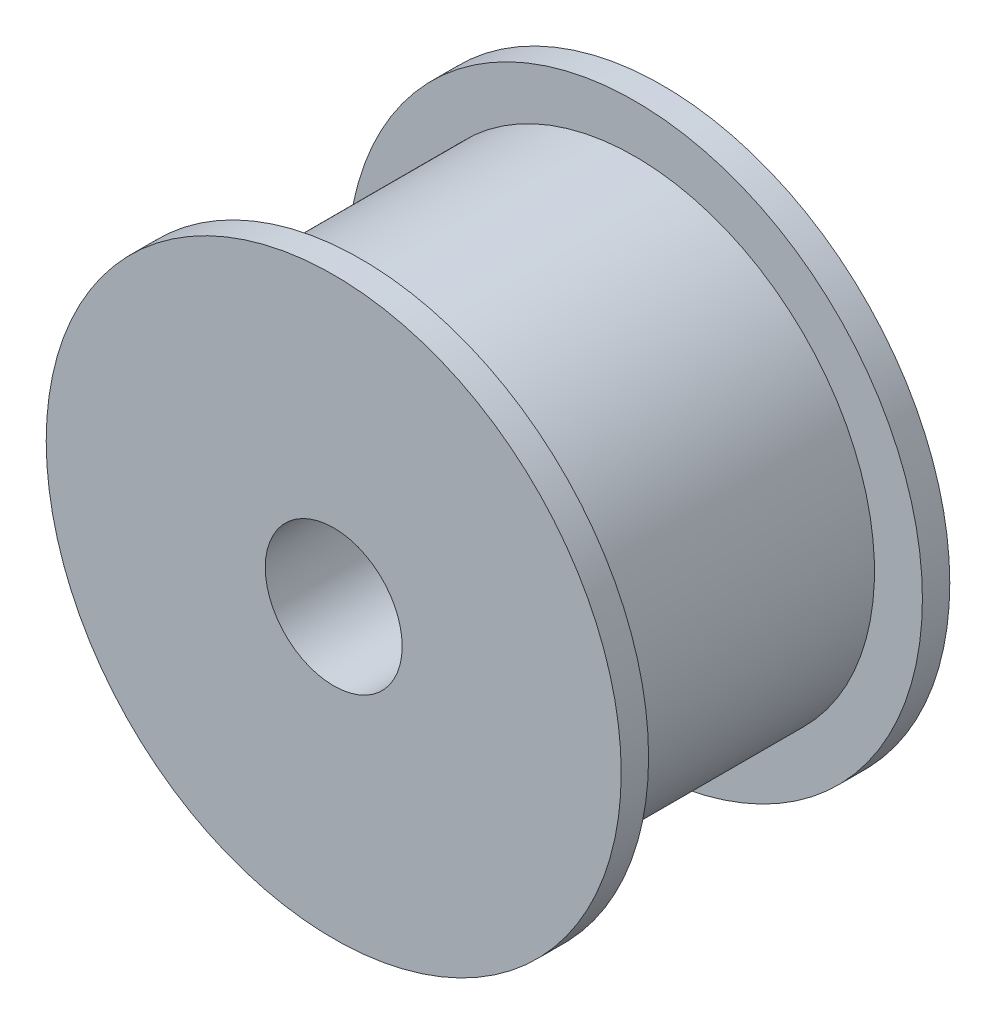
from build123d import *

# Parameters (mm, degrees)
ESQUISSE1_R        = 10.5
ESQUISSE1_R_2      = 2.5
BOSS_EXTRU_1_DEPTH = 1
ESQUISSE2_R        = 8.75
ESQUISSE2_R_2      = 2.5
BOSS_EXTRU_2_DEPTH = 10
ESQUISSE3_R        = 10.5
ESQUISSE3_R_2      = 2.5
BOSS_EXTRU_3_DEPTH = 1


with BuildPart() as part:
    # Esquisse1 → Boss.-Extru.1 (new body)
    with BuildSketch(Plane.XY):
        Circle(ESQUISSE1_R)
        Circle(ESQUISSE1_R_2, mode=Mode.SUBTRACT)
    extrude(amount=BOSS_EXTRU_1_DEPTH)

    # Esquisse2 → Boss.-Extru.2 (add)
    with BuildSketch(Plane(origin=(0, 0, 0), x_dir=(-1, 0, 0), z_dir=(0, 0, -1))):
        Circle(ESQUISSE2_R)
        Circle(ESQUISSE2_R_2, mode=Mode.SUBTRACT)
    extrude(amount=BOSS_EXTRU_2_DEPTH)

    # Esquisse3 → Boss.-Extru.3 (add)
    with BuildSketch(Plane(origin=(0, 0, -10), x_dir=(-1, 0, 0), z_dir=(0, 0, -1))):
        Circle(ESQUISSE3_R)
        Circle(ESQUISSE3_R_2, mode=Mode.SUBTRACT)
    extrude(amount=BOSS_EXTRU_3_DEPTH)


solid = part.part
